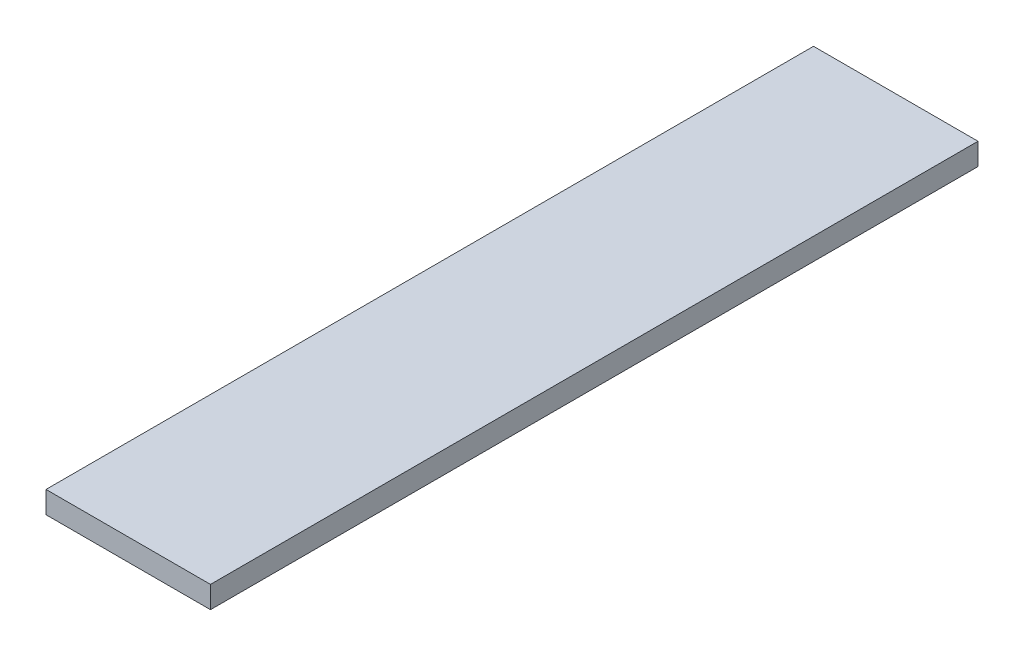
from build123d import *

# Parameters (mm, degrees)
SKETCH1_W           = 150
SKETCH1_H           = 700
BOSS_EXTRUDE1_DEPTH = 20


with BuildPart() as part:
    # Sketch1 → Boss-Extrude1 (new body)
    with BuildSketch(Plane(origin=(0, 0, 0), x_dir=(1, 0, 0), z_dir=(0, 1, 0))):
        with Locations((75, 350)):
            Rectangle(SKETCH1_W, SKETCH1_H)
    extrude(amount=BOSS_EXTRUDE1_DEPTH)


solid = part.part
